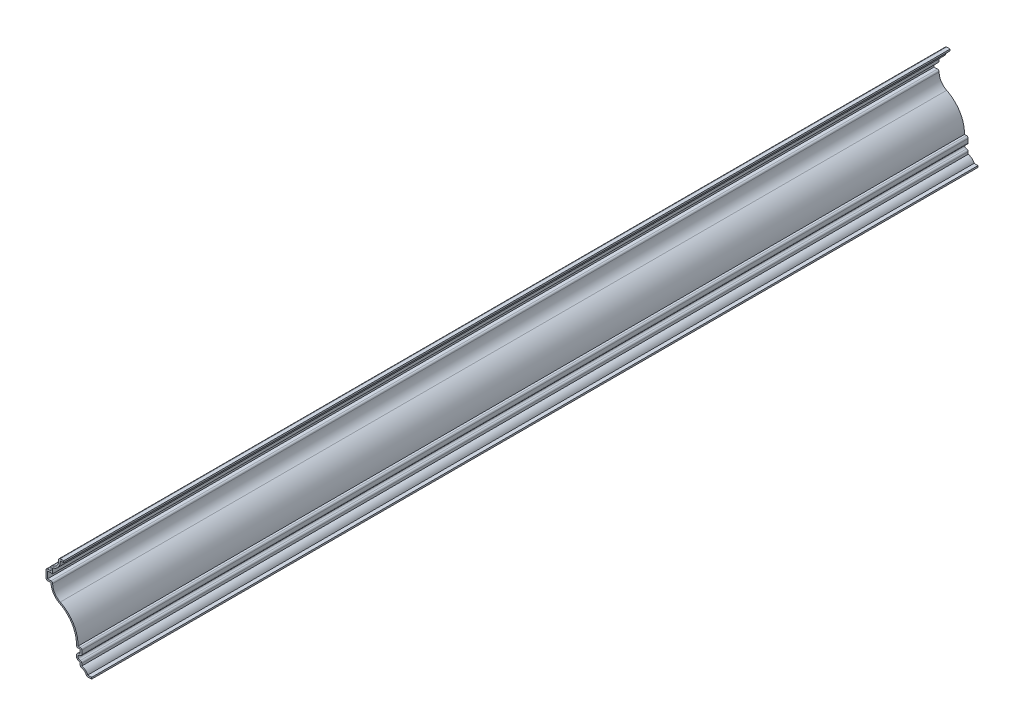
from build123d import *

# Parameters (mm, degrees)
EXTRUDE_THIN1_DEPTH = 555.625
FILLET1_R           = 1.016


with BuildPart() as part:
    # Sketch1 → Extrude-Thin1 (new body)
    with BuildSketch(Plane.XY):
        with BuildLine():
            Line((0, 0), (-3.175, 0))
            ThreePointArc((-3.175, 0), (-4.60251, 2.283581), (-7.14375, 3.175))
            Line((-7.14375, 3.175), (-7.14375, 5.55625))
            ThreePointArc((-7.14375, 5.55625), (-9.525, 7.9375), (-7.14375, 10.31875))
            Line((-7.14375, 10.31875), (-7.14375, 12.7))
            Line((-7.14375, 12.7), (-9.525, 12.7))
            ThreePointArc((-9.525, 12.7), (-11.995981, 23.534537), (-20.091997, 31.146858))
            ThreePointArc((-20.091997, 31.146858), (-23.964886, 34.659641), (-25.4, 39.6875))
            Line((-25.4, 39.6875), (-28.575, 39.6875))
            Line((-28.575, 39.6875), (-28.575, 46.0375))
            Line((-28.575, 46.0375), (-25.4, 46.0375))
            Line((-25.4, 46.0375), (-25.4, 49.2125))
            ThreePointArc((-25.4, 49.2125), (-22.032404, 50.607404), (-20.6375, 53.975))
            Line((-20.6375, 53.975), (-20.6375, 55.5625))
            Line((-20.6375, 55.5625), (-17.4625, 55.5625))
            Line((-17.4625, 55.5625), (-17.4625, 54.5465))
            Line((-17.4625, 54.5465), (-19.6215, 54.5465))
            Line((-19.6215, 54.5465), (-19.6215, 53.975))
            ThreePointArc((-19.6215, 53.975), (-20.969311, 50.265545), (-24.384, 48.28652))
            Line((-24.384, 48.28652), (-24.384, 45.0215))
            Line((-24.384, 45.0215), (-27.559, 45.0215))
            Line((-27.559, 45.0215), (-27.559, 40.7035))
            Line((-27.559, 40.7035), (-24.323126, 40.7035))
            ThreePointArc((-24.323126, 40.7035), (-23.357661, 35.636221), (-19.642184, 32.05786))
            ThreePointArc((-19.642184, 32.05786), (-11.391678, 24.508737), (-8.463037, 13.716))
            Line((-8.463037, 13.716), (-6.12775, 13.716))
            Line((-6.12775, 13.716), (-6.12775, 8.849449))
            ThreePointArc((-6.12775, 8.849449), (-8.509, 7.9375), (-6.12775, 7.025551))
            Line((-6.12775, 7.025551), (-6.12775, 4.088445))
            ThreePointArc((-6.12775, 4.088445), (-3.893771, 3.016555), (-2.431789, 1.016))
            Line((-2.431789, 1.016), (0, 1.016))
            Line((0, 1.016), (0, 0))
        make_face()
    extrude(amount=-EXTRUDE_THIN1_DEPTH)

    # Fillet1
    fillet1_edges = [part.edges().sort_by_distance(p)[0] for p in [
        (-24.323126, 40.7035, -277.8125),
        (-6.12775, 13.716, -277.8125),
        (-6.12775, 8.849449, -277.8125),
        (-6.12775, 7.025551, -277.8125),
        (-3.175, 0, -277.8125),
        (-7.14375, 3.175, -277.8125),
        (-9.525, 12.7, -277.8125),
        (-28.575, 39.6875, -277.8125),
        (-28.575, 46.0375, -277.8125),
        (-25.4, 49.2125, -277.8125),
        (-20.6375, 55.5625, -277.8125),
    ]]
    fillet(fillet1_edges, radius=FILLET1_R)


solid = part.part
